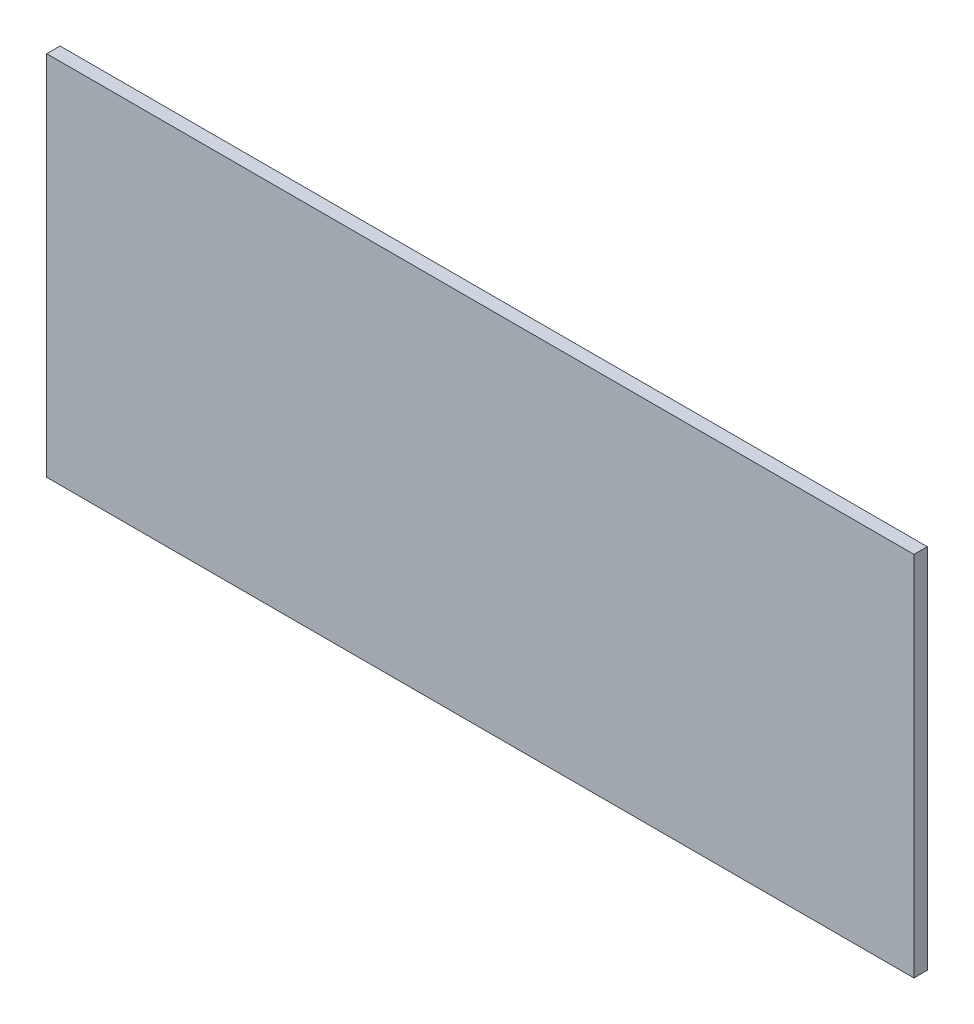
from build123d import *

# Parameters (mm, degrees)
ESQUISSE1_W        = 130
ESQUISSE1_H        = 55
BOSS_EXTRU_1_DEPTH = 2


with BuildPart() as part:
    # Esquisse1 → Boss.-Extru.1 (new body)
    with BuildSketch(Plane.XY):
        Rectangle(ESQUISSE1_W, ESQUISSE1_H)
    extrude(amount=BOSS_EXTRU_1_DEPTH)


solid = part.part
